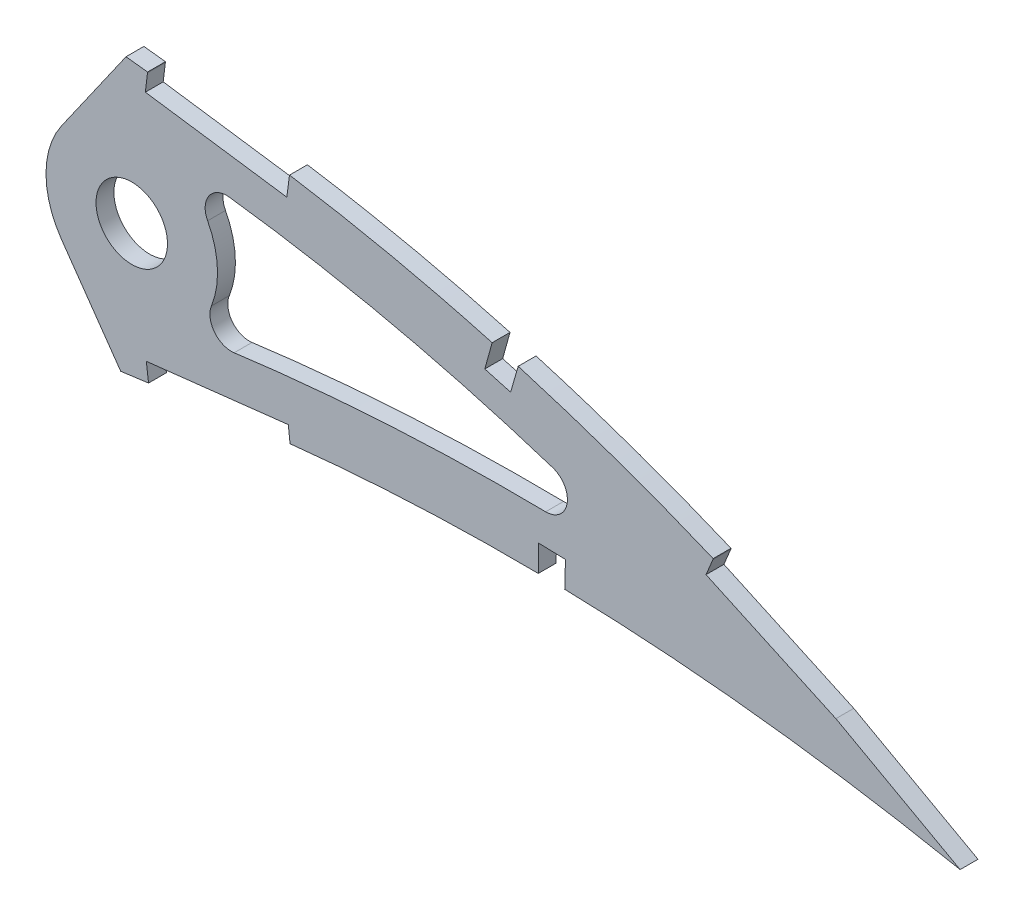
from build123d import *

# Parameters (mm, degrees)
BOSS_EXTRUDE1_DEPTH     = 3.175
SKETCH3_R               = 6.35
CUT_EXTRUDE2_DEPTH      = 7.62
CUT_EXTRUDE3_DEPTH      = 460.680430564
CUT_EXTRUDE3_DEPTH_BACK = 460.680430564
CUT_EXTRUDE4_DEPTH      = 459.987889409
FILLET1_R               = 3.81


with BuildPart() as part:
    # Sketch1 → Boss-Extrude1 (new body)
    with BuildSketch(Plane.XY):
        with BuildLine():
            Line((452.103130844, 0.704841059), (456.093968789, -1.676407199))
            Line((456.093968789, -1.676407199), (451.539257956, -0.704841059))
            add(Edge.make_bspline(
                [(0, 0), (0.116098484, -0.548062271), (0.348829019, -1.646705608), (0.981127511, -3.228296827), (1.817312083, -4.748664111), (2.874932324, -6.203769023), (4.146956076, -7.593213852), (5.630573928, -8.918443806), (7.324330898, -10.17874635), (9.226010202, -11.373547856), (11.332849305, -12.504116729), (13.642480166, -13.569749989), (16.152796843, -14.570114683), (18.861064307, -15.503873502), (21.763971588, -16.372448625), (24.858758771, -17.173723352), (28.141906776, -17.908817596), (31.610257831, -18.575854993), (35.260032504, -19.175513209), (39.087439203, -19.707456616), (43.088549366, -20.172017908), (47.259437594, -20.568222339), (51.595978462, -20.896922095), (56.093849686, -21.158335191), (60.748685259, -21.353290574), (65.556026339, -21.481047186), (70.511164689, -21.543596642), (75.60962225, -21.541878079), (80.846411515, -21.475431763), (86.217059019, -21.347928406), (91.716411041, -21.158560481), (97.339502767, -20.909619435), (103.081262098, -20.60361064), (108.936539298, -20.241571378), (114.900181528, -19.825106256), (120.967010704, -19.35755507), (127.131515672, -18.84008407), (133.388320155, -18.27570942), (139.73188498, -17.667256592), (146.156729407, -17.016651105), (152.657182369, -16.326953548), (159.227454029, -15.600398833), (165.861955098, -14.840863119), (172.554624992, -14.049720613), (179.299804335, -13.231488425), (186.0911476, -12.387729793), (192.922975871, -11.521694689), (199.789144556, -10.637460813), (206.683225759, -9.734927313), (213.599421065, -8.820524357), (220.53106073, -7.893498895), (227.472111233, -6.958618548), (234.416147314, -6.018789286), (241.356405409, -5.07430035), (248.28678484, -4.129065861), (255.200856388, -3.185680808), (262.091847615, -2.244231265), (268.953524037, -1.309396646), (275.778976202, -0.38106275), (282.561910312, 0.538888344), (289.295826346, 1.447710664), (295.974371147, 2.344257157), (302.590655451, 3.227960607), (309.138022785, 4.099152889), (315.511866205, 4.931391047), (321.69553077, 5.768992271), (327.709854245, 6.4556395), (333.649291775, 7.04171769), (339.520012945, 7.522220911), (345.31496828, 7.904062197), (351.027518107, 8.189969928), (356.650854245, 8.383935735), (362.17787359, 8.491713952), (367.601672755, 8.516039607), (372.914848341, 8.464670411), (378.110490176, 8.34174704), (383.181346836, 8.152787103), (388.120344083, 7.904165623), (392.920466429, 7.60266025), (397.574507523, 7.252718477), (402.075982121, 6.8625098), (406.417945063, 6.437746476), (410.593729281, 5.983281443), (414.597241701, 5.508637621), (418.422074216, 5.016940024), (422.062473684, 4.516268978), (425.512580015, 4.011698392), (428.766929364, 3.509669922), (431.820408455, 3.014973074), (434.668085107, 2.534173613), (437.305498365, 2.071763811), (439.728071725, 1.632259415), (441.932444373, 1.221205742), (443.914262697, 0.840644737), (445.670876088, 0.49684807), (447.199018295, 0.19133282), (448.496449148, -0.071596745), (449.560902928, -0.290902855), (450.390762879, -0.462985534), (450.984389878, -0.5881196), (451.34114184, -0.662580877), (451.499651332, -0.696392563), (451.539257956, -0.704841059)],
                knots=[0, 0, 0, 0, 0.003638255, 0.007293231, 0.011028136, 0.014901081, 0.018963272, 0.023258475, 0.027820626, 0.032679082, 0.03785316, 0.043361875, 0.049214679, 0.055422346, 0.061988786, 0.068918036, 0.076211157, 0.083868392, 0.091887411, 0.100265912, 0.108999867, 0.118084529, 0.127514843, 0.13728527, 0.147387917, 0.157816481, 0.168563473, 0.179619128, 0.190977373, 0.202626974, 0.214560478, 0.226767249, 0.239236417, 0.251959004, 0.264923894, 0.278119703, 0.291536035, 0.30516028, 0.318980685, 0.332985499, 0.34716279, 0.361498603, 0.375980747, 0.390597192, 0.405332593, 0.420174823, 0.435109533, 0.450124276, 0.465203068, 0.480333154, 0.495500583, 0.510689775, 0.525887334, 0.541078314, 0.556247233, 0.571381785, 0.58646604, 0.601484515, 0.616424329, 0.631269423, 0.646006524, 0.660620684, 0.675098187, 0.689422858, 0.703581825, 0.716907563, 0.730009274, 0.742952128, 0.755725557, 0.768319951, 0.780724337, 0.792926528, 0.804916041, 0.816679084, 0.828203525, 0.8394749, 0.850481359, 0.861207697, 0.871639326, 0.881763414, 0.891563605, 0.901027365, 0.910138977, 0.918883977, 0.927249278, 0.935221104, 0.942784739, 0.949928188, 0.956638465, 0.962904203, 0.968712288, 0.974054485, 0.978918432, 0.983297219, 0.987180246, 0.990560674, 0.993433357, 0.995790626, 0.997629588, 0.998945816, 0.999736592, 1, 1, 1, 1], degree=3))
            add(Edge.make_bspline(
                [(452.103130844, 0.704841059), (452.068496813, 0.726236426), (451.930095213, 0.811734792), (451.618251437, 1.003015711), (451.098966561, 1.321603382), (450.372013154, 1.765285304), (449.437955605, 2.332883088), (448.296324058, 3.020422222), (446.947831268, 3.825669225), (445.392803438, 4.744815234), (443.631400049, 5.773556989), (441.66429165, 6.907726386), (439.491649667, 8.140902925), (437.114315549, 9.468047233), (434.533105048, 10.882848063), (431.748506266, 12.378914822), (428.761516485, 13.948638114), (425.573282246, 15.58526602), (422.184384898, 17.279761053), (418.59642206, 19.025070833), (414.810589229, 20.812493246), (410.828178709, 22.632492429), (406.65147817, 24.477648573), (402.281642423, 26.336490908), (397.721161703, 28.200965635), (392.971977542, 30.06046153), (388.036901986, 31.906510246), (382.917838926, 33.727152381), (377.618614974, 35.514431666), (372.141800823, 37.256737501), (366.491313143, 38.944607324), (360.670434952, 40.56709799), (354.684018662, 42.115888344), (348.535860801, 43.579699531), (342.231172339, 44.948733274), (335.774964791, 46.214747245), (329.172652762, 47.36510198), (322.442531978, 48.398900537), (315.692888447, 49.25884604), (308.957131835, 50.102255317), (302.231406377, 50.894561333), (295.423478513, 51.653303868), (288.539897863, 52.374211064), (281.587492313, 53.055028822), (274.573300246, 53.692818583), (267.504610588, 54.285710178), (260.388263375, 54.830343915), (253.231762389, 55.325880728), (246.04218283, 55.767964282), (238.827182474, 56.156262652), (231.594085468, 56.488067665), (224.350419046, 56.761093174), (217.103874943, 56.973690929), (209.861975326, 57.123824182), (202.632561324, 57.210549036), (195.423152651, 57.231495803), (188.241586793, 57.186289729), (181.095384018, 57.073378669), (173.992389816, 56.89121691), (166.940134698, 56.63946441), (159.9462446, 56.318230463), (153.018377106, 55.924824851), (146.164047723, 55.461754745), (139.39088931, 54.92707481), (132.706343647, 54.320642895), (126.117416199, 53.644986873), (119.631442696, 52.898268934), (113.255374135, 52.082613865), (106.996184656, 51.199620764), (100.86089724, 50.248808671), (94.856084142, 49.232924024), (88.98822628, 48.153006108), (83.263531815, 47.012221039), (77.688233433, 45.810866329), (72.268232878, 44.552545746), (67.009162956, 43.23945158), (61.916677035, 41.873987713), (56.99593741, 40.459430694), (52.251920045, 38.998989643), (47.690155321, 37.494269359), (43.314090924, 35.950975056), (39.129102409, 34.370202293), (35.138395613, 32.756820932), (31.346647327, 31.113033952), (27.756690145, 29.443852436), (24.372587071, 27.751176724), (21.196749975, 26.039749097), (18.232367129, 24.312193837), (15.482292083, 22.571719722), (12.9476807, 20.82274152), (10.632027491, 19.066357057), (8.536127933, 17.307004609), (6.661308341, 15.547363257), (5.010248609, 13.788645116), (3.582889331, 12.033947283), (2.381101114, 10.284659424), (1.405092396, 8.542436815), (0.657070826, 6.808544998), (0.13629461, 5.083959089), (-0.148774805, 3.371224525), (-0.21973029, 1.668968236), (-0.073133992, 0.555491501), (0, 0)],
                knots=[0, 0, 0, 0, 0.00025409, 0.001015373, 0.002283359, 0.004056577, 0.006330982, 0.009105274, 0.012374489, 0.016134023, 0.02037966, 0.025105976, 0.030306237, 0.035972206, 0.042099522, 0.048678064, 0.055701664, 0.063160184, 0.071045824, 0.079349826, 0.08806291, 0.097175756, 0.106678112, 0.116561573, 0.126814275, 0.137428301, 0.148393618, 0.15969976, 0.171338126, 0.183297699, 0.195569604, 0.208143556, 0.221011593, 0.234161831, 0.24758745, 0.261276822, 0.27522271, 0.289414144, 0.303771199, 0.317689227, 0.331784111, 0.346039677, 0.36044387, 0.37498272, 0.389640454, 0.404403316, 0.419256601, 0.434186749, 0.449177265, 0.464214782, 0.479284009, 0.49436974, 0.509457833, 0.524532346, 0.53957932, 0.554582984, 0.569529546, 0.584403417, 0.599190992, 0.613876838, 0.628447475, 0.642888675, 0.657186054, 0.671325546, 0.685294014, 0.699078147, 0.712665095, 0.726042645, 0.739197713, 0.752117586, 0.764792042, 0.777208152, 0.789355685, 0.80122396, 0.812803686, 0.824082909, 0.835054602, 0.845709571, 0.856037853, 0.866033834, 0.875688843, 0.884997719, 0.893953426, 0.902552897, 0.910789386, 0.918660734, 0.926166253, 0.933302626, 0.94007122, 0.94647478, 0.952517526, 0.958204819, 0.963546652, 0.9685566, 0.973249913, 0.977651041, 0.981787043, 0.985694226, 0.989415109, 0.993001157, 0.996508416, 1, 1, 1, 1], degree=3))
        make_face()
    extrude(amount=BOSS_EXTRUDE1_DEPTH)

    # Sketch3 → Cut-Extrude2 (cut)
    with BuildSketch(Plane(origin=(0, 0, 0), x_dir=(-1, 0, 0), z_dir=(0, 0, -1))):
        with Locations((-299.038447077, 26.255421435)):
            Circle(SKETCH3_R)
    extrude(amount=-CUT_EXTRUDE2_DEPTH, mode=Mode.SUBTRACT)

    # Sketch4 → Cut-Extrude3 (cut, two sides)
    with BuildSketch(Plane.XY.offset(3.175)) as cut_extrude3_sk:
        with BuildLine():
            ThreePointArc((286.554569922, 17.514116545), (283.798447077, 26.255421435), (286.554569922, 34.996726325))
            Line((286.554569922, 34.996726325), (291.360999499, 41.861019145))
            Line((291.360999499, 41.861019145), (298.013920258, 51.362374666))
            add(Edge.make_bspline(
                [(298.013920258, 51.362374666), (297.158172729, 51.45702442), (294.008181803, 51.801525794), (288.539897863, 52.374211064), (281.587492313, 53.055028822), (274.573300246, 53.692818583), (267.504610588, 54.285710178), (260.388263375, 54.830343915), (253.231762389, 55.325880728), (246.04218283, 55.767964282), (238.827182474, 56.156262652), (231.594085468, 56.488067665), (224.350419046, 56.761093174), (217.103874943, 56.973690929), (209.861975326, 57.123824182), (202.632561324, 57.210549036), (195.423152651, 57.231495803), (188.241586793, 57.186289729), (181.095384018, 57.073378669), (173.992389816, 56.89121691), (166.940134698, 56.63946441), (159.9462446, 56.318230463), (154.912407449, 56.032379184), (152.210390737, 55.861831716), (151.817548324, 55.836670076)],
                knots=[0.340665949, 0.340665949, 0.340665949, 0.340665949, 0.346039677, 0.36044387, 0.37498272, 0.389640454, 0.404403316, 0.419256601, 0.434186749, 0.449177265, 0.464214782, 0.479284009, 0.49436974, 0.509457833, 0.524532346, 0.53957932, 0.554582984, 0.569529546, 0.584403417, 0.599190992, 0.613876838, 0.628447475, 0.642888675, 0.645345618, 0.645345618, 0.645345618, 0.645345618], degree=3))
            add(Edge.make_bspline(
                [(151.817548324, 55.836670076), (149.924372746, 55.715411774), (145.771614423, 55.430775666), (139.39088931, 54.92707481), (132.706343647, 54.320642895), (126.117416199, 53.644986873), (119.631442696, 52.898268934), (113.255374135, 52.082613865), (106.996184656, 51.199620764), (100.86089724, 50.248808671), (94.856084142, 49.232924024), (88.98822628, 48.153006108), (83.263531815, 47.012221039), (77.688233433, 45.810866329), (72.268232878, 44.552545746), (67.009162956, 43.23945158), (61.916677035, 41.873987713), (56.99593741, 40.459430694), (52.251920045, 38.998989643), (47.690155321, 37.494269359), (43.314090924, 35.950975056), (39.129102409, 34.370202293), (35.138395613, 32.756820932), (31.346647327, 31.113033952), (27.756690145, 29.443852436), (24.372587071, 27.751176724), (21.196749975, 26.039749097), (18.232367129, 24.312193837), (15.482292083, 22.571719722), (12.9476807, 20.82274152), (10.632027491, 19.066357057), (8.536127933, 17.307004609), (6.661308341, 15.547363257), (5.010248609, 13.788645116), (3.582889331, 12.033947283), (2.381101114, 10.284659424), (1.405092396, 8.542436815), (0.657070826, 6.808544998), (0.13629461, 5.083959089), (-0.148774805, 3.371224525), (-0.21973029, 1.668968236), (-0.073133992, 0.555491501), (0, 0)],
                knots=[0.645345618, 0.645345618, 0.645345618, 0.645345618, 0.657186054, 0.671325546, 0.685294014, 0.699078147, 0.712665095, 0.726042645, 0.739197713, 0.752117586, 0.764792042, 0.777208152, 0.789355685, 0.80122396, 0.812803686, 0.824082909, 0.835054602, 0.845709571, 0.856037853, 0.866033834, 0.875688843, 0.884997719, 0.893953426, 0.902552897, 0.910789386, 0.918660734, 0.926166253, 0.933302626, 0.94007122, 0.94647478, 0.952517526, 0.958204819, 0.963546652, 0.9685566, 0.973249913, 0.977651041, 0.981787043, 0.985694226, 0.989415109, 0.993001157, 0.996508416, 1, 1, 1, 1], degree=3))
            add(Edge.make_bspline(
                [(0, 0), (0.116098484, -0.548062271), (0.348829019, -1.646705608), (0.981127511, -3.228296827), (1.817312083, -4.748664111), (2.874932324, -6.203769023), (4.146956076, -7.593213852), (5.630573928, -8.918443806), (7.324330898, -10.17874635), (9.226010202, -11.373547856), (11.332849305, -12.504116729), (13.642480166, -13.569749989), (16.152796843, -14.570114683), (18.861064307, -15.503873502), (21.763971588, -16.372448625), (24.858758771, -17.173723352), (28.141906776, -17.908817596), (31.610257831, -18.575854993), (35.260032504, -19.175513209), (39.087439203, -19.707456616), (43.088549366, -20.172017908), (47.259437594, -20.568222339), (51.595978462, -20.896922095), (56.093849686, -21.158335191), (60.748685259, -21.353290574), (65.556026339, -21.481047186), (70.511164689, -21.543596642), (75.60962225, -21.541878079), (80.846411515, -21.475431763), (86.217059019, -21.347928406), (91.716411041, -21.158560481), (97.339502767, -20.909619435), (103.081262098, -20.60361064), (108.936539298, -20.241571378), (114.900181528, -19.825106256), (120.967010704, -19.35755507), (127.131515672, -18.84008407), (133.388320155, -18.27570942), (139.73188498, -17.667256592), (146.156729407, -17.016651105), (152.657182369, -16.326953548), (159.227454029, -15.600398833), (164.423185784, -15.00557734), (167.428285856, -14.653970639), (168.221856304, -14.560625117)],
                knots=[0, 0, 0, 0, 0.003638255, 0.007293231, 0.011028136, 0.014901081, 0.018963272, 0.023258475, 0.027820626, 0.032679082, 0.03785316, 0.043361875, 0.049214679, 0.055422346, 0.061988786, 0.068918036, 0.076211157, 0.083868392, 0.091887411, 0.100265912, 0.108999867, 0.118084529, 0.127514843, 0.13728527, 0.147387917, 0.157816481, 0.168563473, 0.179619128, 0.190977373, 0.202626974, 0.214560478, 0.226767249, 0.239236417, 0.251959004, 0.264923894, 0.278119703, 0.291536035, 0.30516028, 0.318980685, 0.332985499, 0.34716279, 0.361498603, 0.375980747, 0.381177933, 0.381177933, 0.381177933, 0.381177933], degree=3))
            add(Edge.make_bspline(
                [(168.221856304, -14.560625117), (169.660104846, -14.391447873), (173.347852421, -13.953497195), (179.299804335, -13.231488425), (186.0911476, -12.387729793), (192.922975871, -11.521694689), (199.789144556, -10.637460813), (206.683225759, -9.734927313), (213.599421065, -8.820524357), (220.53106073, -7.893498895), (227.472111233, -6.958618548), (234.416147314, -6.018789286), (241.356405409, -5.07430035), (248.28678484, -4.129065861), (255.200856388, -3.185680808), (262.091847615, -2.244231265), (268.953524037, -1.309396646), (275.778976202, -0.38106275), (282.561910312, 0.538888344), (289.295826346, 1.447710664), (294.127893032, 2.096380782), (296.714481339, 2.44258854), (297.074078933, 2.490700718)],
                knots=[0.381177933, 0.381177933, 0.381177933, 0.381177933, 0.390597192, 0.405332593, 0.420174823, 0.435109533, 0.450124276, 0.465203068, 0.480333154, 0.495500583, 0.510689775, 0.525887334, 0.541078314, 0.556247233, 0.571381785, 0.58646604, 0.601484515, 0.616424329, 0.631269423, 0.646006524, 0.660620684, 0.662980449, 0.662980449, 0.662980449, 0.662980449], degree=3))
            Line((297.074078933, 2.490700718), (290.512280083, 11.861920667))
            Line((290.512280083, 11.861920667), (286.554569922, 17.514116545))
        make_face()
        with BuildLine():
            add(Edge.make_bspline(
                [(397.099522024, 17.473424975), (391.104870759, 19.944342333), (379.177241568, 24.454975752), (361.031599335, 30.108120681), (345.827122006, 33.867334113), (333.567983327, 36.314328103), (325.822177912, 37.620830237), (319.688308692, 38.50590344), (314.963719571, 39.109215878), (310.159271505, 39.713456799), (306.795732769, 40.122713606), (305.012513563, 40.334581661), (304.815814132, 40.357890364)],
                knots=[0.119621685, 0.119621685, 0.119621685, 0.119621685, 0.161336405, 0.201670506, 0.242004607, 0.262171657, 0.282338708, 0.292422233, 0.302505759, 0.312589284, 0.322672809, 0.323922714, 0.323922714, 0.323922714, 0.323922714], degree=3))
            ThreePointArc((304.815814132, 40.357890364), (311.693577932, 34.746903228), (314.278447077, 26.255421435))
            ThreePointArc((314.278447077, 26.255421435), (312.737622507, 19.577832608), (308.426715772, 14.250505321))
            add(Edge.make_bspline(
                [(308.426715772, 14.250505321), (309.883764278, 14.442106028), (312.813862177, 14.824905538), (317.172571012, 15.411601995), (321.750889037, 16.002865885), (327.831130307, 16.688761643), (335.429886376, 17.415497246), (347.62570179, 18.27521734), (362.899139077, 18.793639217), (380.425060388, 18.544010551), (391.813646799, 17.883889315), (397.099522024, 17.473424975)],
                knots=[0.690710776, 0.690710776, 0.690710776, 0.690710776, 0.700258061, 0.709927156, 0.719596251, 0.729265346, 0.748603535, 0.767941725, 0.806618104, 0.845294483, 0.878913441, 0.878913441, 0.878913441, 0.878913441], degree=3))
        make_face()
    extrude(amount=CUT_EXTRUDE3_DEPTH, mode=Mode.SUBTRACT)
    extrude(cut_extrude3_sk.sketch, amount=-CUT_EXTRUDE3_DEPTH_BACK, mode=Mode.SUBTRACT)

    # Sketch5 → Cut-Extrude4 (cut, through all)
    with BuildSketch(Plane.XY.offset(3.175)):
        Polygon((301.451819787, 47.624682834), (326.581608557, 44.037650574), (326.99921232, 47.184972745), (301.82606159, 50.777059573), align=None)
        with BuildLine():
            Line((301.82606159, 50.777059573), (326.99921232, 47.184972745))
            Line((326.99921232, 47.184972745), (327.069816491, 47.679762966))
            add(Edge.make_bspline(
                [(327.069816491, 47.679762966), (325.536616389, 47.92066491), (321.726527159, 48.490123892), (315.692888447, 49.25884604), (308.957131835, 50.102255317), (304.363753308, 50.643365932), (301.984106736, 50.91571996), (301.848065805, 50.931263918)],
                knots=[0.279727575, 0.279727575, 0.279727575, 0.279727575, 0.289414144, 0.303771199, 0.317689227, 0.331784111, 0.332638735, 0.332638735, 0.332638735, 0.332638735], degree=3))
            Line((301.848065805, 50.931263918), (301.82606159, 50.777059573))
        make_face()
        Polygon((363.042315163, 39.775006099), (361.761863334, 35.188407664), (366.348461768, 33.907955828), (367.660879003, 38.44902397), align=None)
        with BuildLine():
            add(Edge.make_bspline(
                [(367.697022743, 38.574917199), (367.309131435, 38.688520556), (365.770845604, 39.13592881), (364.229260686, 39.571916139), (363.074849178, 39.891543449)],
                knots=[0.193046912, 0.193046912, 0.193046912, 0.193046912, 0.195569604, 0.203045851, 0.203045851, 0.203045851, 0.203045851], degree=3))
            Line((363.074849178, 39.891543449), (363.042315163, 39.775006099))
            Line((363.042315163, 39.775006099), (367.660879003, 38.44902397))
            Line((367.660879003, 38.44902397), (367.697022743, 38.574917199))
        make_face()
        with BuildLine():
            add(Edge.make_bspline(
                [(452.103130844, 0.704841059), (452.068496813, 0.726236426), (451.930095213, 0.811734792), (451.618251437, 1.003015711), (451.098966561, 1.321603382), (450.372013154, 1.765285304), (449.437955605, 2.332883088), (448.296324058, 3.020422222), (446.947831268, 3.825669225), (445.392803438, 4.744815234), (443.631400049, 5.773556989), (441.66429165, 6.907726386), (439.491649667, 8.140902925), (437.114315549, 9.468047233), (434.533105048, 10.882848063), (431.748506266, 12.378914822), (428.761516485, 13.948638114), (425.573282246, 15.58526602), (422.184384898, 17.279761053), (418.59642206, 19.025070833), (414.810589229, 20.812493246), (410.828178709, 22.632492429), (406.653948307, 24.476557332), (403.798247458, 25.691356866), (402.339340059, 26.300103121)],
                knots=[0, 0, 0, 0, 0.00025409, 0.001015373, 0.002283359, 0.004056577, 0.006330982, 0.009105274, 0.012374489, 0.016134023, 0.02037966, 0.025105976, 0.030306237, 0.035972206, 0.042099522, 0.048678064, 0.055701664, 0.063160184, 0.071045824, 0.079349826, 0.08806291, 0.097175756, 0.106678112, 0.116544718, 0.116544718, 0.116544718, 0.116544718], degree=3))
            Line((402.339340059, 26.300103121), (402.290686885, 26.125826692))
            Line((402.290686885, 26.125826692), (401.073116455, 23.194323723))
            Line((401.073116455, 23.194323723), (424.143893957, 12.576896143))
            Line((424.143893957, 12.576896143), (446.221524037, 0.386409338))
            add(Edge.make_bspline(
                [(446.221524037, 0.386409338), (446.283176157, 0.374132159), (446.344825696, 0.361842003), (446.406472734, 0.349539293)],
                knots=[0.98823034, 0.98823034, 0.98823034, 0.98823034, 0.988639216, 0.988639216, 0.988639216, 0.988639216], degree=3))
            add(Edge.make_bspline(
                [(446.406472734, 0.349539293), (446.696174778, 0.291724346), (447.418859044, 0.14678121), (448.496449148, -0.071596745), (449.560902928, -0.290902855), (450.390762879, -0.462985534), (450.984389878, -0.5881196), (451.34114184, -0.662580877), (451.499651332, -0.696392563), (451.539257956, -0.704841059)],
                knots=[0.988639216, 0.988639216, 0.988639216, 0.988639216, 0.990560674, 0.993433357, 0.995790626, 0.997629588, 0.998945816, 0.999736592, 1, 1, 1, 1], degree=3))
            Line((451.539257956, -0.704841059), (456.093968789, -1.676407199))
            Line((456.093968789, -1.676407199), (452.103130844, 0.704841059))
        make_face()
        with BuildLine():
            Line((403.140773054, 29.170848615), (402.339340059, 26.300103121))
            add(Edge.make_bspline(
                [(452.103130844, 0.704841059), (452.068496813, 0.726236426), (451.930095213, 0.811734792), (451.618251437, 1.003015711), (451.098966561, 1.321603382), (450.372013154, 1.765285304), (449.437955605, 2.332883088), (448.296324058, 3.020422222), (446.947831268, 3.825669225), (445.392803438, 4.744815234), (443.631400049, 5.773556989), (441.66429165, 6.907726386), (439.491649667, 8.140902925), (437.114315549, 9.468047233), (434.533105048, 10.882848063), (431.748506266, 12.378914822), (428.761516485, 13.948638114), (425.573282246, 15.58526602), (422.184384898, 17.279761053), (418.59642206, 19.025070833), (414.810589229, 20.812493246), (410.828178709, 22.632492429), (406.653948307, 24.476557332), (403.798247458, 25.691356866), (402.339340059, 26.300103121)],
                knots=[0, 0, 0, 0, 0.00025409, 0.001015373, 0.002283359, 0.004056577, 0.006330982, 0.009105274, 0.012374489, 0.016134023, 0.02037966, 0.025105976, 0.030306237, 0.035972206, 0.042099522, 0.048678064, 0.055701664, 0.063160184, 0.071045824, 0.079349826, 0.08806291, 0.097175756, 0.106678112, 0.116544718, 0.116544718, 0.116544718, 0.116544718], degree=3))
            Line((452.103130844, 0.704841059), (456.093968789, -1.676407199))
            Line((456.093968789, -1.676407199), (451.539257956, -0.704841059))
            add(Edge.make_bspline(
                [(446.406472734, 0.349539293), (446.696174778, 0.291724346), (447.418859044, 0.14678121), (448.496449148, -0.071596745), (449.560902928, -0.290902855), (450.390762879, -0.462985534), (450.984389878, -0.5881196), (451.34114184, -0.662580877), (451.499651332, -0.696392563), (451.539257956, -0.704841059)],
                knots=[0.988639216, 0.988639216, 0.988639216, 0.988639216, 0.990560674, 0.993433357, 0.995790626, 0.997629588, 0.998945816, 0.999736592, 1, 1, 1, 1], degree=3))
            Line((446.406472734, 0.349539293), (446.378861202, 0.299533317))
            Line((446.378861202, 0.299533317), (476.345105152, -16.246767176))
            Line((476.345105152, -16.246767176), (476.345105152, 29.170848615))
            Line((476.345105152, 29.170848615), (403.140773054, 29.170848615))
        make_face()
        with BuildLine():
            Line((371.335577488, 13.177143516), (371.266974819, 8.476219756))
            add(Edge.make_bspline(
                [(371.266974819, 8.476219756), (371.829182551, 8.469327849), (373.396733052, 8.446604514), (374.964119693, 8.414074315), (375.969273317, 8.38919082)],
                knots=[0.824546523, 0.824546523, 0.824546523, 0.824546523, 0.828203525, 0.834743274, 0.834743274, 0.834743274, 0.834743274], degree=3))
            Line((375.969273317, 8.38919082), (376.095538591, 13.048083319))
            Line((376.095538591, 13.048083319), (371.335577488, 13.177143516))
        make_face()
        with BuildLine():
            Line((301.617807304, 6.296804494), (302.022573182, 3.151661284))
            add(Edge.make_bspline(
                [(302.022573182, 3.151661284), (302.219722219, 3.177952509), (304.59990003, 3.495310563), (309.138022785, 4.099152889), (315.511866205, 4.931391047), (321.505771517, 5.743288648), (325.352162282, 6.186274623), (327.164526706, 6.381783897)],
                knots=[0.673804524, 0.673804524, 0.673804524, 0.673804524, 0.675098187, 0.689422858, 0.703581825, 0.716907563, 0.728763791, 0.728763791, 0.728763791, 0.728763791], degree=3))
            Line((327.164526706, 6.381783897), (326.846064837, 9.169096855))
            Line((326.846064837, 9.169096855), (301.617807304, 6.296804494))
        make_face()
    extrude(amount=-CUT_EXTRUDE4_DEPTH, mode=Mode.SUBTRACT)

    # Fillet1
    fillet1_edges = [part.edges().sort_by_distance(p)[0] for p in [
        (397.099522024, 17.473424975, 1.5875),
        (304.815814132, 40.357890364, 1.5875),
        (308.426715772, 14.250505321, 1.5875),
    ]]
    fillet(fillet1_edges, radius=FILLET1_R)


solid = part.part
